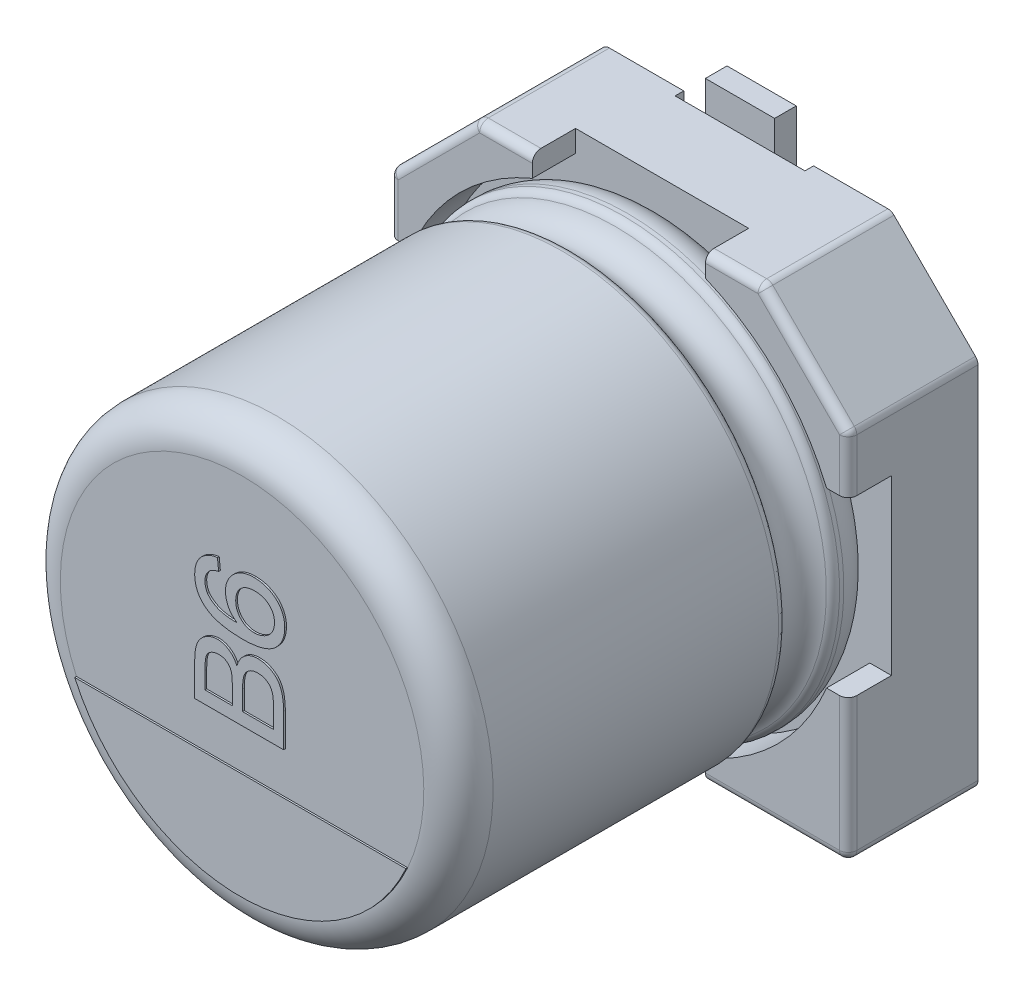
from build123d import *

# Parameters (mm, degrees)
BOSS_EXTRUDE1_DEPTH  = 1
BOSS_EXTRUDE2_DEPTH  = 0.5
SKETCH7_R            = 0.35
SPACER_PAD_DEPTH     = 0.15
SKETCH9_W            = 1.5
SKETCH9_H            = 2.05
CUT_EXTRUDE1_DEPTH   = 0.1
FILLET1_R            = 0.1
FILLET2_R            = 0.1
CATHODE_MARKER_DEPTH = 0.02
TEXT_2_DEPTH         = 0.02
SKETCH19_W           = 0.8
SKETCH19_H           = 2.3
BOSS_EXTRUDE6_DEPTH  = 0.25


with BuildPart() as part:
    # Sketch2 → Boss-Extrude1 (new body)
    with BuildSketch(Plane.XY):
        Polygon((-2.65, 1.65), (-1.65, 2.65), (1.65, 2.65), (2.65, 1.65), (2.65, -2.65), (-2.65, -2.65), align=None)
    extrude(amount=BOSS_EXTRUDE1_DEPTH)

    # Sketch4 → Boss-Extrude2 (add)
    with BuildSketch(Plane.XY.offset(1)):
        with BuildLine():
            Line((-2.65, 1.65), (-1.65, 2.65))
            Line((-1.65, 2.65), (-1, 2.65))
            Line((-1, 2.65), (-1, 2.4))
            ThreePointArc((-1, 2.4), (-1.838477631, 1.838477631), (-2.4, 1))
            Line((-2.4, 1), (-2.65, 1))
            Line((-2.65, 1), (-2.65, 1.65))
        make_face()
        with BuildLine():
            Line((1.65, 2.65), (2.65, 1.65))
            Line((2.65, 1.65), (2.65, 1))
            Line((2.65, 1), (2.4, 1))
            ThreePointArc((2.4, 1), (1.838477631, 1.838477631), (1, 2.4))
            Line((1, 2.4), (1, 2.65))
            Line((1, 2.65), (1.65, 2.65))
        make_face()
        with BuildLine():
            Line((2.65, -1), (2.65, -2.65))
            Line((2.65, -2.65), (1, -2.65))
            Line((1, -2.65), (1, -2.4))
            ThreePointArc((1, -2.4), (1.838477631, -1.838477631), (2.4, -1))
            Line((2.4, -1), (2.65, -1))
        make_face()
        with BuildLine():
            Line((-2.65, -1), (-2.65, -2.65))
            Line((-2.65, -2.65), (-1, -2.65))
            Line((-1, -2.65), (-1, -2.4))
            ThreePointArc((-1, -2.4), (-1.838477631, -1.838477631), (-2.4, -1))
            Line((-2.4, -1), (-2.65, -1))
        make_face()
    extrude(amount=BOSS_EXTRUDE2_DEPTH)

    # Sketch7 → Spacer pad (add)
    with BuildSketch(Plane(origin=(0, 0, 0), x_dir=(1, 0, 0), z_dir=(0, 0, -1))):
        with Locations((-1.706464504, 1.780616828)):
            Circle(SKETCH7_R)
        with Locations((1.706464504, 1.780616828)):
            Circle(SKETCH7_R)
        with Locations((-1.706464504, -1.780616828)):
            Circle(SKETCH7_R)
        with Locations((1.706464504, -1.780616828)):
            Circle(SKETCH7_R)
    extrude(amount=SPACER_PAD_DEPTH)

    # Sketch9 → Cut-Extrude1 (cut)
    with BuildSketch(Plane(origin=(0, 0, 0), x_dir=(1, 0, 0), z_dir=(0, 0, -1))):
        with Locations((0, 1.625)):
            Rectangle(SKETCH9_W, SKETCH9_H)
        with Locations((0, -1.625)):
            Rectangle(SKETCH9_W, SKETCH9_H)
    extrude(amount=-CUT_EXTRUDE1_DEPTH, mode=Mode.SUBTRACT)

    # Fillet1
    fillet1_edges = [part.edges().sort_by_distance(p)[0] for p in [
        (2.65, -2.65, 0.75),
        (-2.65, -2.65, 0.75),
        (-2.65, 1.65, 0.75),
        (-1.65, 2.65, 0.75),
        (1.65, 2.65, 0.75),
        (2.65, 1.65, 0.75),
    ]]
    fillet(fillet1_edges, radius=FILLET1_R)

    # Sketch10 → Revolve1 (revolve)
    with BuildSketch(Plane(origin=(0, 0, 0), x_dir=(0, 0, -1), z_dir=(1, 0, 0))):
        with BuildLine():
            Line((-5.853626625, 0), (-1, 0))
            Line((-1, 0), (-1, 2.1))
            ThreePointArc((-1, 2.1), (-1.117157288, 2.382842712), (-1.4, 2.5))
            Line((-1.4, 2.5), (-1.449422929, 2.5))
            ThreePointArc((-1.449422929, 2.5), (-1.504479696, 2.483479053), (-1.541344666, 2.439375046))
            ThreePointArc((-1.541344666, 2.439375046), (-1.801990181, 2.267472047), (-2.062635697, 2.439375046))
            ThreePointArc((-2.062635697, 2.439375046), (-2.099500666, 2.483479053), (-2.154557434, 2.5))
            Line((-2.154557434, 2.5), (-5.453626625, 2.5))
            ThreePointArc((-5.453626625, 2.5), (-5.736469337, 2.382842712), (-5.853626625, 2.1))
            Line((-5.853626625, 2.1), (-5.853626625, 0))
        make_face()
    revolve(axis=Axis((0, 0, -18.9630778), (0, 0, 1)))

    # Fillet2
    fillet2_edges = [part.edges().sort_by_distance(p)[0] for p in [
        (1.775, -2.65, 1.5),
        (2.620710678, -2.620710678, 1.5),
        (2.65, 1.304289322, 1.5),
        (2.642387953, 1.646846987, 1.5),
        (1.304289322, 2.65, 1.5),
        (1.646846987, 2.642387953, 1.5),
        (-1.304289322, 2.65, 1.5),
        (-1.646846987, 2.642387953, 1.5),
        (-2.15, 2.15, 1.5),
        (-2.642387953, 1.646846987, 1.5),
        (-2.65, -1.775, 1.5),
        (-2.620710678, -2.620710678, 1.5),
        (2.65, -1.775, 1.5),
        (2.15, 2.15, 1.5),
        (-2.65, 1.304289322, 1.5),
        (-1.775, -2.65, 1.5),
    ]]
    fillet(fillet2_edges, radius=FILLET2_R)

    # Sketch13 → Cathode marker (add)
    with BuildSketch(Plane.XY.offset(5.853626625)):
        with BuildLine():
            Line((-1.913855111, -0.864383373), (1.913855111, -0.864383373))
            ThreePointArc((1.913855111, -0.864383373), (0, -2.1), (-1.913855111, -0.864383373))
        make_face()
    extrude(amount=CATHODE_MARKER_DEPTH)

    # Sketch15 → Text 2 (add)
    with BuildSketch(Plane.XY.offset(5.853626625)):
        with BuildLine():
            Line((0.5, -0.381462215), (-0.527327474, -0.381462215))
            Line((-0.527327474, -0.381462215), (-0.527327474, 0.003168204))
            add(Edge.make_bspline(
                [(-0.527327474, 0.003168204), (-0.527290717, 0.01270636), (-0.527218993, 0.031318013), (-0.525435682, 0.058495585), (-0.522985215, 0.084232148), (-0.519864973, 0.108594991), (-0.515203413, 0.131421033), (-0.510007893, 0.152847584), (-0.503547417, 0.172769308), (-0.493850422, 0.197174841), (-0.478858618, 0.22527196), (-0.456554247, 0.255486594), (-0.42953471, 0.281451499), (-0.398937505, 0.303298385), (-0.365968091, 0.320855467), (-0.331634079, 0.333525804), (-0.296591305, 0.341562985), (-0.272869746, 0.34247842), (-0.261029046, 0.342935363)],
                knots=[0, 0, 0, 0, 0.939498507, 1.83322867, 2.681897829, 3.486672795, 4.251434503, 4.975927433, 5.657710531, 6.312810905, 7.561503051, 8.78340726, 9.997379925, 11.237114968, 12.476665788, 13.665547382, 14.834749792, 16, 16, 16, 16], degree=3))
            add(Edge.make_bspline(
                [(-0.261029046, 0.342935363), (-0.250011795, 0.342456944), (-0.228083509, 0.341504717), (-0.195791826, 0.3338975), (-0.164452036, 0.321988176), (-0.134533509, 0.304845724), (-0.106205397, 0.283401117), (-0.080853185, 0.256452451), (-0.058252406, 0.224810157), (-0.046213451, 0.201048151), (-0.040005467, 0.188795083)],
                knots=[0, 0, 0, 0, 0.926794087, 1.844653005, 2.778994443, 3.741202323, 4.738235586, 5.759634266, 6.84473753, 8, 8, 8, 8], degree=3))
            add(Edge.make_bspline(
                [(-0.040005467, 0.188795083), (-0.037632906, 0.196374195), (-0.032987835, 0.211212808), (-0.024487656, 0.232544518), (-0.014810322, 0.252569761), (-0.003933945, 0.271326135), (0.008220594, 0.288708468), (0.021719111, 0.304552622), (0.036091165, 0.319298785), (0.05179313, 0.332452024), (0.068483581, 0.344173647), (0.085940968, 0.35447653), (0.104115802, 0.363168962), (0.123010111, 0.370169876), (0.142597687, 0.375790947), (0.162988536, 0.379652616), (0.184121122, 0.381942906), (0.198436358, 0.382277744), (0.205713484, 0.382447958)],
                knots=[0, 0, 0, 0, 1.127307071, 2.207075445, 3.256908754, 4.282608941, 5.282408985, 6.263870425, 7.234983269, 8.202720022, 9.167413107, 10.127917746, 11.077645759, 12.02382113, 12.985756818, 13.967604811, 14.966835385, 16, 16, 16, 16], degree=3))
            add(Edge.make_bspline(
                [(0.205713484, 0.382447958), (0.217395478, 0.382090996), (0.24055061, 0.381383454), (0.274577135, 0.375775238), (0.307266025, 0.366145697), (0.338182008, 0.353072263), (0.366803673, 0.3373151), (0.392516408, 0.31974045), (0.414524106, 0.30003744), (0.433230976, 0.278429061), (0.448991358, 0.254539518), (0.462701269, 0.228145192), (0.47407658, 0.198844873), (0.483603425, 0.166640407), (0.490956494, 0.131189302), (0.496169968, 0.092198005), (0.499536429, 0.049462345), (0.499841158, 0.019707252), (0.5, 0.004197178)],
                knots=[0, 0, 0, 0, 1.028330587, 2.038276349, 3.026510127, 4.022742207, 4.987888112, 5.899430057, 6.75924801, 7.58151675, 8.409137447, 9.27369529, 10.195744353, 11.172390338, 12.227965724, 13.380380624, 14.634502938, 16, 16, 16, 16], degree=3))
            Line((0.5, 0.004197178), (0.5, -0.381462215))
        make_face()
        with BuildLine():
            Line((-0.092688927, -0.236582699), (-0.092688927, -0.024819884))
            add(Edge.make_bspline(
                [(-0.092688927, -0.024819884), (-0.092716343, -0.017890478), (-0.092769014, -0.004577523), (-0.093503406, 0.014626098), (-0.094129947, 0.03235012), (-0.095702518, 0.048525983), (-0.097242782, 0.063233825), (-0.099316216, 0.076414786), (-0.101652507, 0.088133427), (-0.103819592, 0.095308753), (-0.104830819, 0.098656976)],
                knots=[0, 0, 0, 0, 1.335841395, 2.566453063, 3.705076039, 4.753984432, 5.69893722, 6.555639608, 7.326018133, 8, 8, 8, 8], degree=3))
            add(Edge.make_bspline(
                [(-0.104830819, 0.098656976), (-0.107586686, 0.106524055), (-0.112899423, 0.121690138), (-0.124964923, 0.142014786), (-0.1394444, 0.159322952), (-0.156589347, 0.173580371), (-0.176267117, 0.184470891), (-0.198117365, 0.192717906), (-0.2225133, 0.197061911), (-0.239473973, 0.19771642), (-0.248269771, 0.198055848)],
                knots=[0, 0, 0, 0, 1.058963388, 2.041459808, 2.989631347, 3.919899374, 4.862262268, 5.840402388, 6.880033636, 8, 8, 8, 8], degree=3))
            add(Edge.make_bspline(
                [(-0.248269771, 0.198055848), (-0.256725679, 0.197792007), (-0.273205268, 0.197277811), (-0.297190772, 0.192885827), (-0.319541154, 0.185429521), (-0.340166349, 0.175254589), (-0.358320253, 0.16221444), (-0.374056808, 0.146882527), (-0.385954594, 0.128412073), (-0.393383059, 0.111160081), (-0.3980288, 0.095640548), (-0.400777732, 0.081774838), (-0.40319973, 0.066046843), (-0.405258858, 0.04840498), (-0.406856923, 0.02884252), (-0.408126483, 0.007299205), (-0.408665507, -0.016173688), (-0.408747264, -0.032434165), (-0.408789689, -0.040871876)],
                knots=[0, 0, 0, 0, 1.216068086, 2.369976461, 3.493683542, 4.597268122, 5.665547116, 6.698540011, 7.738863855, 8.804266032, 9.391389623, 10.067014162, 10.836237155, 11.681038179, 12.622079446, 13.660200056, 14.785856327, 16, 16, 16, 16], degree=3))
            Line((-0.408789689, -0.040871876), (-0.408789689, -0.236582699))
            Line((-0.408789689, -0.236582699), (-0.092688927, -0.236582699))
        make_face(mode=Mode.SUBTRACT)
        with BuildLine():
            Line((0.381462215, -0.236582699), (0.381462215, 0.00646092))
            add(Edge.make_bspline(
                [(0.381462215, 0.00646092), (0.381484832, 0.016136213), (0.381526394, 0.033915621), (0.380319467, 0.058190637), (0.379278955, 0.077889877), (0.37736069, 0.089337184), (0.37652314, 0.094335285)],
                knots=[0, 0, 0, 0, 1.317202051, 2.420502769, 3.310362904, 4, 4, 4, 4], degree=3))
            add(Edge.make_bspline(
                [(0.37652314, 0.094335285), (0.375015878, 0.101506259), (0.372097428, 0.115391117), (0.365583707, 0.134965361), (0.358122051, 0.152912741), (0.348638549, 0.168918766), (0.337711467, 0.183743445), (0.324055183, 0.196613959), (0.308522486, 0.208557578), (0.290674963, 0.218651008), (0.271126067, 0.227137103), (0.249945426, 0.23342024), (0.227226675, 0.236818801), (0.211623463, 0.237315036), (0.203655536, 0.237568443)],
                knots=[0, 0, 0, 0, 1.067698777, 2.067340877, 3.003877398, 3.896034939, 4.774344843, 5.679862112, 6.622203941, 7.625991775, 8.661044271, 9.724611217, 10.838051383, 12, 12, 12, 12], degree=3))
            add(Edge.make_bspline(
                [(0.203655536, 0.237568443), (0.194301669, 0.237284162), (0.176060673, 0.236729786), (0.149694951, 0.231486363), (0.125208163, 0.222745995), (0.102888915, 0.210632864), (0.082875153, 0.195653316), (0.066157801, 0.177386468), (0.052693765, 0.15632723), (0.04215918, 0.132097155), (0.034649875, 0.103795536), (0.029559612, 0.070619356), (0.026273602, 0.032044863), (0.025996503, 0.00447923), (0.025848858, -0.010208456)],
                knots=[0, 0, 0, 0, 0.961566064, 1.875151983, 2.752549789, 3.62736036, 4.478590523, 5.312795546, 6.160536385, 7.03915408, 8.020336805, 9.164452039, 10.489146263, 12, 12, 12, 12], degree=3))
            Line((0.025848858, -0.010208456), (0.025848858, -0.236582699))
            Line((0.025848858, -0.236582699), (0.381462215, -0.236582699))
        make_face(mode=Mode.SUBTRACT)
        with BuildLine():
            Line((-0.263910173, 1.159528996), (-0.250739308, 1.027820346))
            add(Edge.make_bspline(
                [(-0.250739308, 1.027820346), (-0.262066955, 1.024978179), (-0.283389506, 1.019628238), (-0.31231033, 1.008409461), (-0.336772429, 0.996046608), (-0.349944593, 0.985305975), (-0.356106228, 0.980281755)],
                knots=[0, 0, 0, 0, 1.199207122, 2.257322842, 3.184815751, 4, 4, 4, 4], degree=3))
            add(Edge.make_bspline(
                [(-0.356106228, 0.980281755), (-0.360308802, 0.975969046), (-0.368574291, 0.967486946), (-0.379348416, 0.953562425), (-0.388476794, 0.938883674), (-0.395872165, 0.92340633), (-0.401714084, 0.907214007), (-0.405800816, 0.890239634), (-0.408330736, 0.872521664), (-0.408635402, 0.860449081), (-0.408789689, 0.854335358)],
                knots=[0, 0, 0, 0, 1.028360939, 2.022547923, 3.001693811, 3.976902288, 4.948369586, 5.937776631, 6.955661634, 8, 8, 8, 8], degree=3))
            add(Edge.make_bspline(
                [(-0.408789689, 0.854335358), (-0.408470554, 0.844423961), (-0.407839958, 0.824839474), (-0.401666469, 0.796105531), (-0.392426858, 0.768196796), (-0.383060608, 0.750906303), (-0.378332063, 0.74217721)],
                knots=[0, 0, 0, 0, 1.010336883, 1.996381556, 2.988474728, 4, 4, 4, 4], degree=3))
            add(Edge.make_bspline(
                [(-0.378332063, 0.74217721), (-0.371220994, 0.733590642), (-0.35662367, 0.715964471), (-0.329665846, 0.69303825), (-0.298406295, 0.672355853), (-0.269070379, 0.657169312), (-0.242664987, 0.646611209), (-0.220084591, 0.639654055), (-0.195186335, 0.63376625), (-0.167978967, 0.628849424), (-0.138433528, 0.625049974), (-0.106533319, 0.621873319), (-0.072196841, 0.620116598), (-0.048513373, 0.6197253), (-0.036301161, 0.619523529)],
                knots=[0, 0, 0, 0, 1.063250814, 2.182599524, 3.36380985, 4.638540699, 5.329632219, 6.077757597, 6.893023137, 7.772089793, 8.717285182, 9.73761699, 10.83341823, 12, 12, 12, 12], degree=3))
            add(Edge.make_bspline(
                [(-0.036301161, 0.619523529), (-0.047211061, 0.627288581), (-0.068567854, 0.642489145), (-0.096501329, 0.6693049), (-0.120124585, 0.69858338), (-0.138947726, 0.730371433), (-0.153668192, 0.763769922), (-0.163762394, 0.79825812), (-0.170639914, 0.83341557), (-0.171354352, 0.857183762), (-0.171714118, 0.869152581)],
                knots=[0, 0, 0, 0, 1.084001636, 2.121999332, 3.126469213, 4.123683166, 5.106931922, 6.075998312, 7.03114091, 8, 8, 8, 8], degree=3))
            add(Edge.make_bspline(
                [(-0.171714118, 0.869152581), (-0.171436912, 0.879455638), (-0.170889239, 0.899811286), (-0.166549178, 0.929787279), (-0.158958131, 0.958525441), (-0.149068989, 0.986274714), (-0.13556661, 1.012502242), (-0.119785478, 1.037846613), (-0.100584882, 1.061726638), (-0.078998478, 1.08442191), (-0.055003426, 1.105188826), (-0.029048993, 1.123280182), (-0.001458965, 1.138727552), (0.027936119, 1.151009362), (0.059003446, 1.160741805), (0.091724958, 1.167688759), (0.126168435, 1.171870457), (0.149656836, 1.172419151), (0.161673404, 1.172699861)],
                knots=[0, 0, 0, 0, 0.981582189, 1.939302258, 2.87789191, 3.810544529, 4.740168451, 5.683209003, 6.65100384, 7.654285831, 8.664634098, 9.669256765, 10.664156186, 11.671836555, 12.699357328, 13.762200315, 14.855150938, 16, 16, 16, 16], degree=3))
            add(Edge.make_bspline(
                [(0.161673404, 1.172699861), (0.177551784, 1.172180464), (0.208955034, 1.171153234), (0.255125626, 1.163121923), (0.299579783, 1.14993059), (0.334753634, 1.134334073), (0.361740804, 1.119955391), (0.380617593, 1.107749441), (0.398356819, 1.094697035), (0.415202853, 1.081046364), (0.430384613, 1.065807082), (0.444617472, 1.049903147), (0.457409357, 1.032808855), (0.469185898, 1.015026974), (0.479397361, 0.996221589), (0.488471349, 0.976939888), (0.496200717, 0.957023146), (0.502269576, 0.936407053), (0.507290467, 0.915197195), (0.510742792, 0.893322976), (0.512871929, 0.870841966), (0.513070448, 0.855643534), (0.513170865, 0.84795572)],
                knots=[0, 0, 0, 0, 1.777960384, 3.516337103, 5.232817765, 6.960340972, 7.816514579, 8.656393217, 9.475627613, 10.283429005, 11.082224935, 11.882498067, 12.672484914, 13.471761235, 14.269669532, 15.067244712, 15.857866702, 16.660166545, 17.47288749, 18.29786845, 19.139011754, 20, 20, 20, 20], degree=3))
            add(Edge.make_bspline(
                [(0.513170865, 0.84795572), (0.512810832, 0.83497244), (0.512104743, 0.809509945), (0.506680251, 0.772241859), (0.497615162, 0.736854181), (0.484941143, 0.703271636), (0.468940454, 0.671391921), (0.448882488, 0.641529205), (0.425361994, 0.613518247), (0.398242561, 0.587337453), (0.366927773, 0.563599351), (0.3307809, 0.543311699), (0.290118349, 0.526024819), (0.244828247, 0.511877012), (0.194863231, 0.501171207), (0.14033061, 0.493462575), (0.081222574, 0.488721852), (0.040263709, 0.488124271), (0.019057631, 0.487814879)],
                knots=[0, 0, 0, 0, 0.898506621, 1.76212948, 2.600594211, 3.422599815, 4.24233914, 5.064166416, 5.906856258, 6.769969817, 7.668413694, 8.619051846, 9.63165591, 10.722000005, 11.898403521, 13.164960021, 14.532183992, 16, 16, 16, 16], degree=3))
            add(Edge.make_bspline(
                [(0.019057631, 0.487814879), (0.006982207, 0.48786618), (-0.016834658, 0.487967365), (-0.051887147, 0.489593305), (-0.085738797, 0.491458459), (-0.118254557, 0.494654107), (-0.149580671, 0.498427328), (-0.179532919, 0.503490941), (-0.208344113, 0.50892865), (-0.235787414, 0.515539796), (-0.262120992, 0.522909607), (-0.287055498, 0.531392516), (-0.310913542, 0.540352569), (-0.333318762, 0.550517563), (-0.354636063, 0.561351079), (-0.374470963, 0.573325944), (-0.393276992, 0.585884325), (-0.40487338, 0.595155443), (-0.410641841, 0.599767232)],
                knots=[0, 0, 0, 0, 1.28053818, 2.525659045, 3.721026795, 4.875695215, 5.990149104, 7.066600796, 8.096771069, 9.099076143, 10.059445332, 10.995815448, 11.891625124, 12.761078582, 13.603822678, 14.426062074, 15.217066536, 16, 16, 16, 16], degree=3))
            add(Edge.make_bspline(
                [(-0.410641841, 0.599767232), (-0.419973797, 0.608063756), (-0.438367949, 0.624416977), (-0.462128836, 0.652392196), (-0.482424289, 0.682202148), (-0.498821258, 0.714322266), (-0.511604862, 0.748507054), (-0.520884625, 0.784777944), (-0.526266247, 0.823236147), (-0.526967998, 0.849516486), (-0.527327474, 0.862978738)],
                knots=[0, 0, 0, 0, 1.005002357, 1.980952959, 2.948226316, 3.90482984, 4.879026092, 5.883055346, 6.915583142, 8, 8, 8, 8], degree=3))
            add(Edge.make_bspline(
                [(-0.527327474, 0.862978738), (-0.527150278, 0.873002879), (-0.526802163, 0.892696112), (-0.523461959, 0.921551725), (-0.517879309, 0.948998484), (-0.510348939, 0.975097519), (-0.500325055, 0.999697072), (-0.488445667, 1.023080746), (-0.47415551, 1.045011098), (-0.457649818, 1.065329365), (-0.439396485, 1.084085874), (-0.419242227, 1.100885818), (-0.397438235, 1.115665897), (-0.373939162, 1.128541691), (-0.348856244, 1.139398145), (-0.32208168, 1.148311833), (-0.293622348, 1.155086831), (-0.273951515, 1.15802775), (-0.263910173, 1.159528996)],
                knots=[0, 0, 0, 0, 1.095988384, 2.15315746, 3.171326302, 4.156539379, 5.119213808, 6.072133135, 7.021027441, 7.975952916, 8.930907862, 9.879001051, 10.840359051, 11.807350428, 12.805278655, 13.825435679, 14.889953203, 16, 16, 16, 16], degree=3))
        make_face()
        with BuildLine():
            add(Edge.make_bspline(
                [(0.158998072, 0.619523529), (0.169310164, 0.619891877), (0.189798968, 0.620623736), (0.220157625, 0.626149633), (0.249735881, 0.635325396), (0.278297889, 0.647722233), (0.304884941, 0.663190657), (0.328595717, 0.68133744), (0.348808335, 0.702112787), (0.365426018, 0.725379103), (0.378336608, 0.750827556), (0.38802361, 0.778094634), (0.393612374, 0.80739236), (0.394287705, 0.827558512), (0.39463308, 0.837871776)],
                knots=[0, 0, 0, 0, 1.034371533, 2.055163721, 3.085036369, 4.136219926, 5.172765015, 6.164074703, 7.123048089, 8.070464312, 9.021723619, 9.977430468, 10.965628467, 12, 12, 12, 12], degree=3))
            add(Edge.make_bspline(
                [(0.39463308, 0.837871776), (0.394434279, 0.845222528), (0.394046237, 0.859570545), (0.391039304, 0.880578372), (0.386415535, 0.90062216), (0.379583948, 0.91958585), (0.370864964, 0.937443707), (0.360253388, 0.954288454), (0.347717449, 0.970109198), (0.33328016, 0.984714652), (0.317223299, 0.997914823), (0.2996454, 1.009384022), (0.280835665, 1.019512396), (0.260331852, 1.02713055), (0.238659248, 1.033338242), (0.215612932, 1.037902081), (0.191166443, 1.040581535), (0.174370852, 1.040852675), (0.165789299, 1.040991211)],
                knots=[0, 0, 0, 0, 1.023436885, 1.997658284, 2.950132304, 3.883974581, 4.798406504, 5.712938251, 6.651509614, 7.604127386, 8.56812849, 9.540661787, 10.523651728, 11.536824179, 12.580180944, 13.661349568, 14.805088061, 16, 16, 16, 16], degree=3))
            add(Edge.make_bspline(
                [(0.165789299, 1.040991211), (0.157548441, 1.040862997), (0.141432403, 1.040612258), (0.117917662, 1.037780985), (0.095680484, 1.033675849), (0.074880784, 1.02728632), (0.055300216, 1.01968936), (0.037270196, 1.00979911), (0.020427558, 0.998472969), (0.005087373, 0.985305576), (-0.00877089, 0.970776782), (-0.020533854, 0.954695506), (-0.030711117, 0.937582661), (-0.038997353, 0.919083013), (-0.045364198, 0.899265204), (-0.049772296, 0.878151497), (-0.052850552, 0.855865954), (-0.053066074, 0.840558155), (-0.053176332, 0.832726907)],
                knots=[0, 0, 0, 0, 1.155514215, 2.259753865, 3.318605965, 4.323374797, 5.308078351, 6.25972982, 7.201991692, 8.150865321, 9.090370884, 10.012362416, 10.939962465, 11.879024295, 12.84989812, 13.854113716, 14.902195686, 16, 16, 16, 16], degree=3))
            add(Edge.make_bspline(
                [(-0.053176332, 0.832726907), (-0.053062563, 0.825443836), (-0.05283837, 0.811091851), (-0.049736111, 0.790044831), (-0.04531916, 0.769758671), (-0.03888687, 0.750319558), (-0.030625647, 0.731701627), (-0.020514143, 0.714015169), (-0.008629831, 0.697104049), (0.005026041, 0.681265279), (0.020125409, 0.666633207), (0.036657323, 0.654025123), (0.05435757, 0.643539526), (0.072922127, 0.634518415), (0.092831288, 0.627725747), (0.113895406, 0.6230967), (0.136070496, 0.62011598), (0.151236642, 0.619724085), (0.158998072, 0.619523529)],
                knots=[0, 0, 0, 0, 1.036834006, 2.043179957, 3.024920909, 3.992398523, 4.95507473, 5.922552344, 6.890671636, 7.895735102, 8.898133371, 9.881478754, 10.850387221, 11.825341133, 12.817584876, 13.839615819, 14.894401237, 16, 16, 16, 16], degree=3))
        make_face(mode=Mode.SUBTRACT)
    extrude(amount=TEXT_2_DEPTH)

    # Sketch19 → Boss-Extrude6 (add)
    with BuildSketch(Plane(origin=(0, 0, 0.1), x_dir=(1, 0, 0), z_dir=(0, 0, -1))):
        with Locations((0, 1.85)):
            Rectangle(SKETCH19_W, SKETCH19_H)
        with Locations((0, -1.85)):
            Rectangle(SKETCH19_W, SKETCH19_H)
    extrude(amount=BOSS_EXTRUDE6_DEPTH)


solid = part.part
